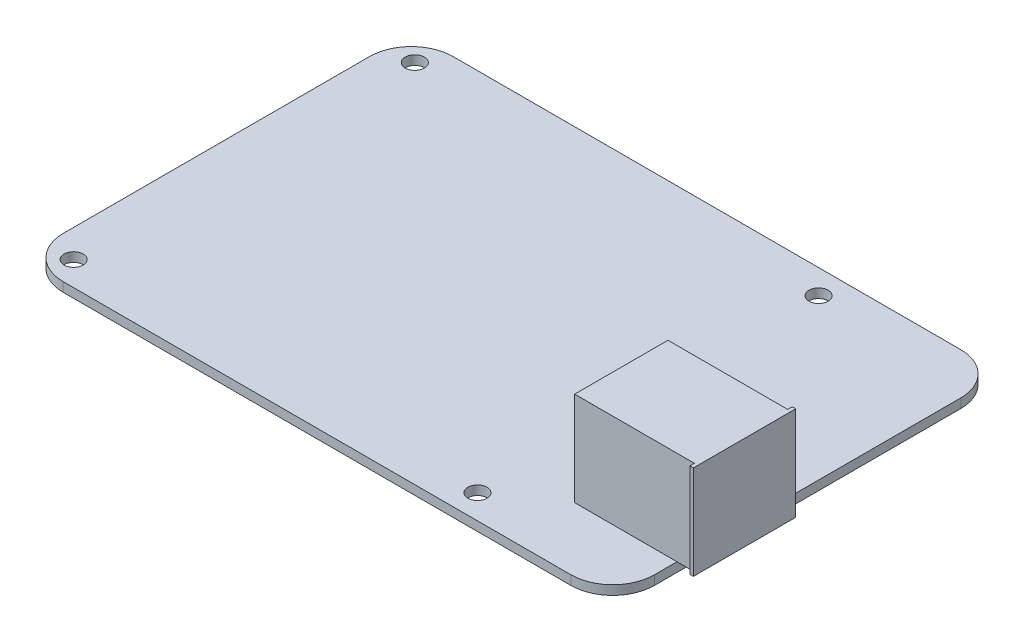
from build123d import *

# Parameters (mm, degrees)
CROQUIS1_W              = 84.92
CROQUIS1_H              = 56
SALIENTE_EXTRUIR1_DEPTH = 1.33
REDONDEO1_R             = 6
CROQUIS2_R              = 1.375
CORTAR_EXTRUIR1_DEPTH   = 1.33
SALIENTE_EXTRUIR2_DEPTH = 13.5


with BuildPart() as part:
    # Croquis1 → Saliente-Extruir1 (new body)
    with BuildSketch(Plane(origin=(0, 0, 0), x_dir=(1, 0, 0), z_dir=(0, 1, 0))):
        Rectangle(CROQUIS1_W, CROQUIS1_H)
    extrude(amount=SALIENTE_EXTRUIR1_DEPTH)

    # Redondeo1
    redondeo1_edges = [part.edges().sort_by_distance(p)[0] for p in [
        (42.46, 0.665, 28),
        (-42.46, 0.665, 28),
        (-42.46, 0.665, -28),
        (42.46, 0.665, -28),
    ]]
    fillet(redondeo1_edges, radius=REDONDEO1_R)

    # Croquis2 → Cortar-Extruir1 (cut)
    with BuildSketch(Plane(origin=(0, 1.33, 0), x_dir=(1, 0, 0), z_dir=(0, 1, 0))):
        with Locations((-38.46, 24.5)):
            Circle(CROQUIS2_R)
        with Locations((-38.46, -24.5)):
            Circle(CROQUIS2_R)
        with Locations((19.54, -24.5)):
            Circle(CROQUIS2_R)
        with Locations((19.54, 24.5)):
            Circle(CROQUIS2_R)
    extrude(amount=-CORTAR_EXTRUIR1_DEPTH, mode=Mode.SUBTRACT)

    # Croquis3 → Saliente-Extruir2 (add)
    with BuildSketch(Plane(origin=(0, 1.33, 0), x_dir=(1, 0, 0), z_dir=(0, 1, 0))):
        Polygon((45.46, -18.762058392), (45.46, -19.412058392), (44.96, -19.412058392), (44.96, -18.762058392), (27.76, -18.762058392), (27.76, -5.362058392), (44.96, -5.362058392), (44.96, -4.712058392), (45.46, -4.712058392), (45.46, -5.362058392), align=None)
    extrude(amount=SALIENTE_EXTRUIR2_DEPTH)


solid = part.part
